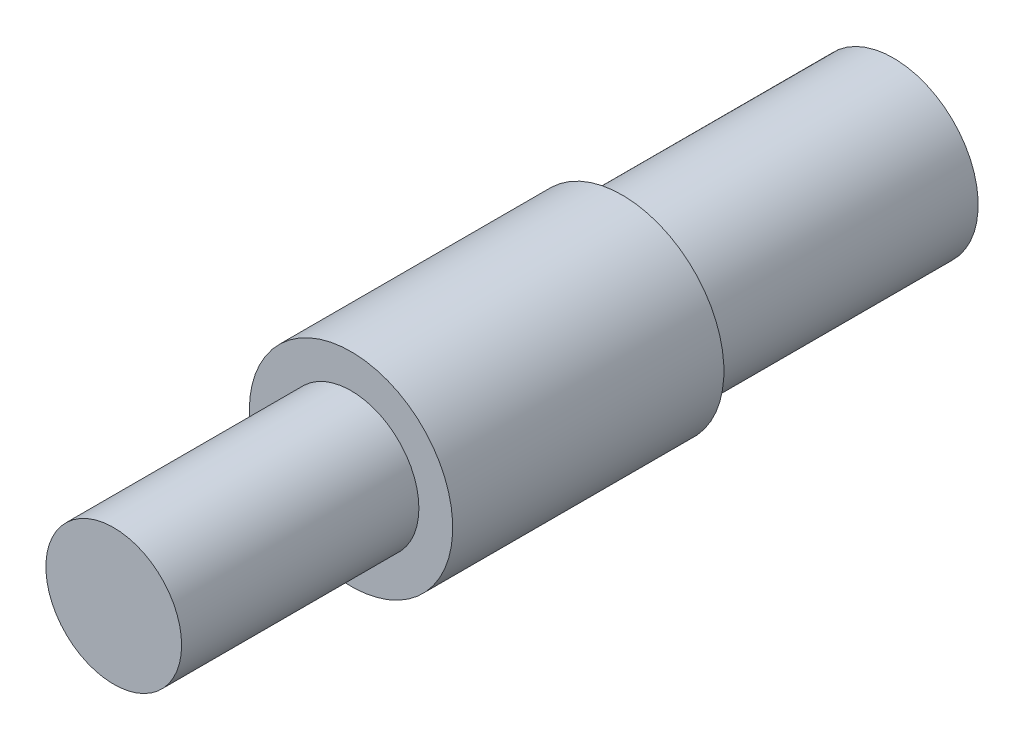
from build123d import *

# Parameters (mm, degrees)
SKETCH2_R           = 10.01
BOSS_EXTRUDE1_DEPTH = 35
SKETCH3_R           = 15
BOSS_EXTRUDE2_DEPTH = 40
SKETCH4_R           = 12.5
BOSS_EXTRUDE3_DEPTH = 40


with BuildPart() as part:
    # Sketch2 → Boss-Extrude1 (new body)
    with BuildSketch(Plane.XY):
        Circle(SKETCH2_R)
    extrude(amount=-BOSS_EXTRUDE1_DEPTH)

    # Sketch3 → Boss-Extrude2 (add)
    with BuildSketch(Plane(origin=(0, 0, -35), x_dir=(-1, 0, 0), z_dir=(0, 0, -1))):
        Circle(SKETCH3_R)
    extrude(amount=BOSS_EXTRUDE2_DEPTH)

    # Sketch4 → Boss-Extrude3 (add)
    with BuildSketch(Plane(origin=(0, 0, -75), x_dir=(-1, 0, 0), z_dir=(0, 0, -1))):
        Circle(SKETCH4_R)
    extrude(amount=BOSS_EXTRUDE3_DEPTH)


solid = part.part
